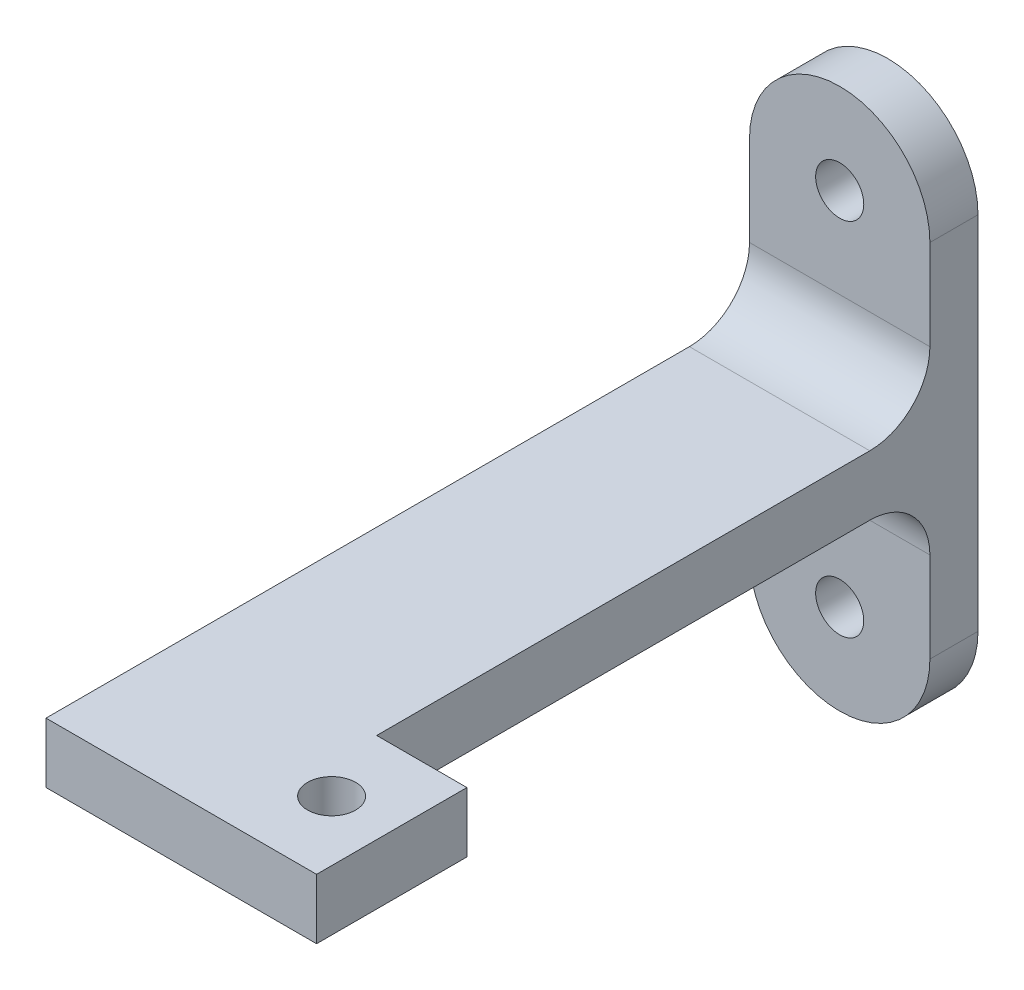
from build123d import *

# Parameters (mm, degrees)
SKETCH1_R           = 4
BOSS_EXTRUDE1_DEPTH = 8
SKETCH2_W           = 30
SKETCH2_H           = 10
BOSS_EXTRUDE2_DEPTH = 100
FILLET1_R           = 10
SKETCH5_W           = 45
SKETCH5_H           = 25
SKETCH5_R           = 4
BOSS_EXTRUDE4_DEPTH = 10


with BuildPart() as part:
    # Sketch1 → Boss-Extrude1 (new body)
    with BuildSketch(Plane.XY):
        with BuildLine():
            Line((15, 30), (15, -30))
            ThreePointArc((15, -30), (0, -45), (-15, -30))
            Line((-15, -30), (-15, 30))
            ThreePointArc((-15, 30), (0, 45), (15, 30))
        make_face()
        with Locations((0, 30)):
            Circle(SKETCH1_R, mode=Mode.SUBTRACT)
        with Locations((0, -30)):
            Circle(SKETCH1_R, mode=Mode.SUBTRACT)
    extrude(amount=BOSS_EXTRUDE1_DEPTH)

    # Sketch2 → Boss-Extrude2 (add)
    with BuildSketch(Plane.XY):
        Rectangle(SKETCH2_W, SKETCH2_H)
    extrude(amount=BOSS_EXTRUDE2_DEPTH)

    # Fillet1
    fillet1_edges = [part.edges().sort_by_distance(p)[0] for p in [
        (0, 5, 8),
        (0, -5, 8),
    ]]
    fillet(fillet1_edges, radius=FILLET1_R)

    # Sketch5 → Boss-Extrude4 (add)
    with BuildSketch(Plane(origin=(0, 5, 0), x_dir=(1, 0, 0), z_dir=(0, 1, 0))):
        with Locations((7.5, -112.5)):
            Rectangle(SKETCH5_W, SKETCH5_H)
        with Locations((20, -112.5)):
            Circle(SKETCH5_R, mode=Mode.SUBTRACT)
    extrude(amount=-BOSS_EXTRUDE4_DEPTH)


solid = part.part
